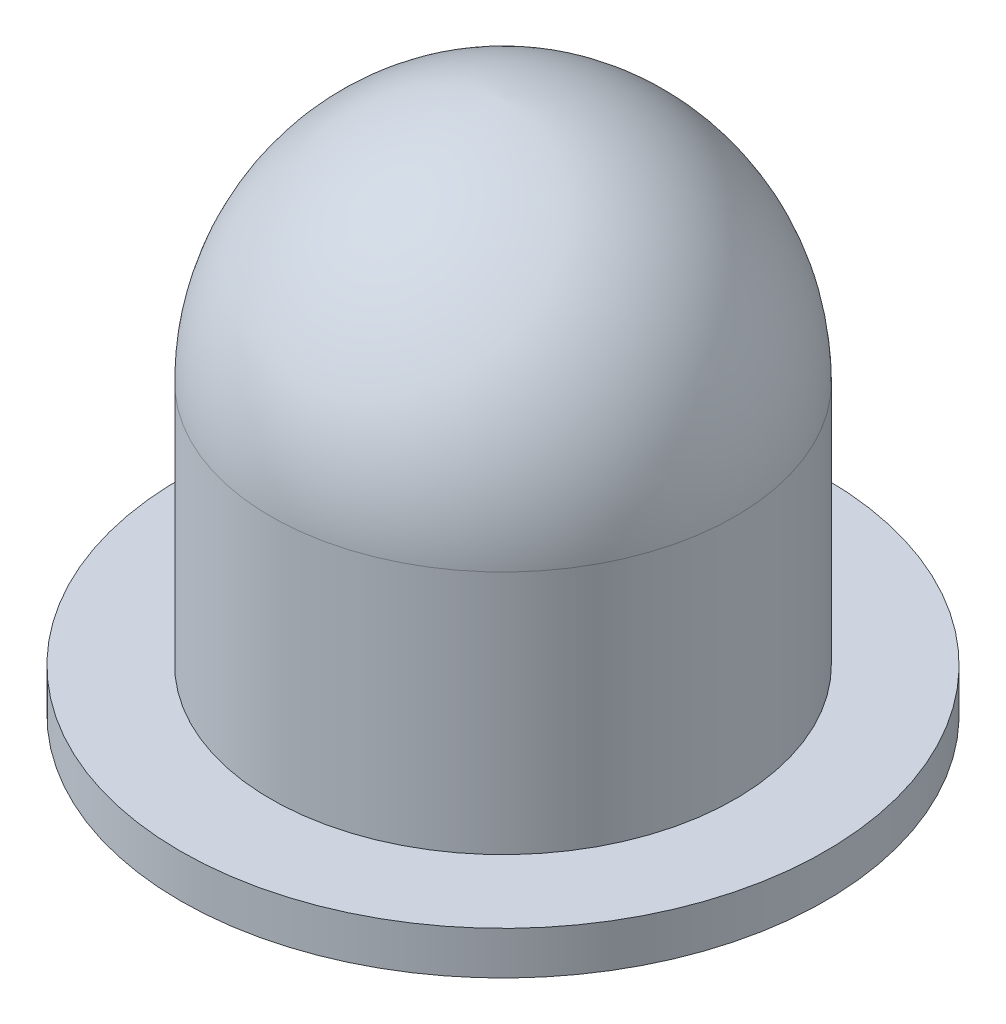
from build123d import *

# Parameters (mm, degrees)
SKETCH2_W = 13.335
SKETCH2_H = 6.35


with BuildPart() as part:
    # Sketch2 → Revolve2 (revolve)
    with BuildSketch(Plane.XY, mode=Mode.PRIVATE) as revolve2_sk:
        with BuildLine():
            Line((0, 0), (0, 85.09))
            ThreePointArc((0, 85.09), (24.35925855, 73.790400632), (34.29, 48.841757438))
            Line((34.29, 48.841757438), (34.29, 0))
            Line((34.29, 0), (0, 0))
        make_face()
        with Locations((40.9575, 9.525)):
            Rectangle(SKETCH2_W, SKETCH2_H)
    revolve(revolve2_sk.sketch.rotate(Axis((0, 0, 0), (0, 1, 0)), 90), axis=Axis((0, 0, 0), (0, 1, 0)))  # turned: the seam where the file's is


solid = part.part
